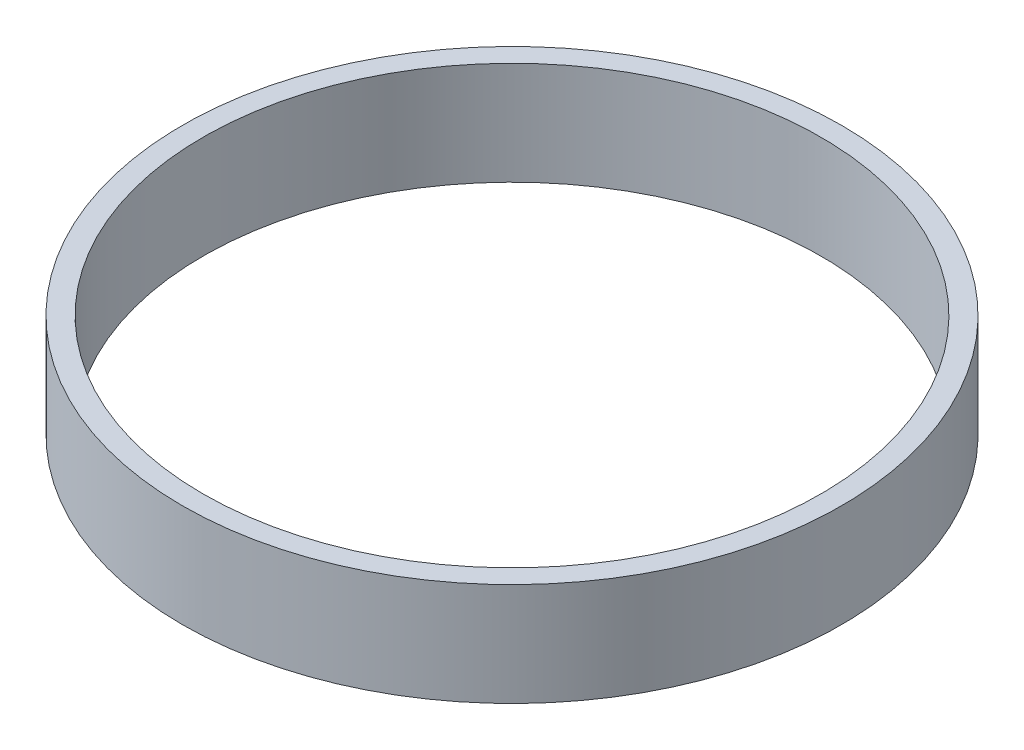
from build123d import *

# Parameters (mm, degrees)
SKETCH1_R           = 32
SKETCH1_R_2         = 30
BOSS_EXTRUDE1_DEPTH = 10


with BuildPart() as part:
    # Sketch1 → Boss-Extrude1 (new body)
    with BuildSketch(Plane(origin=(0, 0, 0), x_dir=(1, 0, 0), z_dir=(0, 1, 0))):
        with Locations(Location((0, 0, 0), (0, 0, 270))):  # turned: the seam where the file's is
            Circle(SKETCH1_R)
        with Locations(Location((0, 0, 0), (0, 0, 270))):  # turned: the seam where the file's is
            Circle(SKETCH1_R_2, mode=Mode.SUBTRACT)
    extrude(amount=BOSS_EXTRUDE1_DEPTH)


solid = part.part
